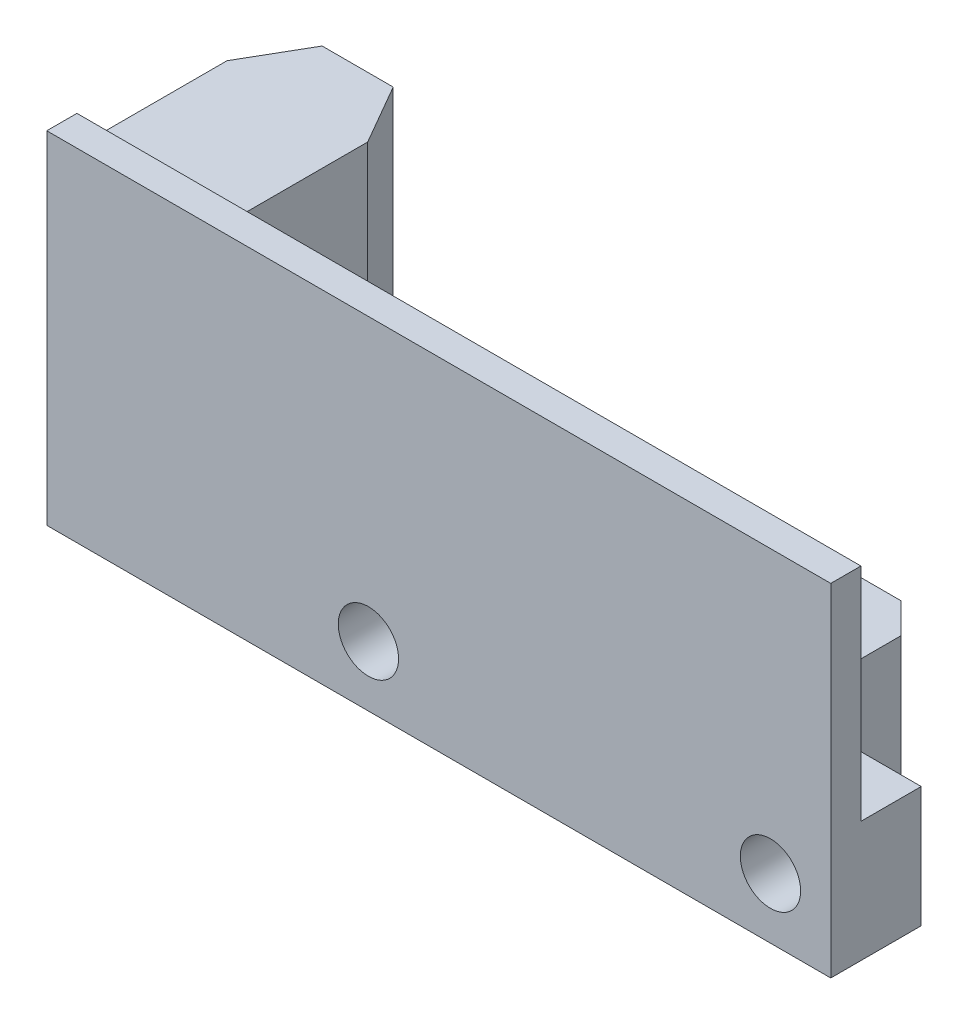
from build123d import *

# Parameters (mm, degrees)
ESQUISSE1_W             = 39
ESQUISSE1_H             = 17
BOSS_EXTRU_1_DEPTH      = 1.5
BOSS_EXTRU_2_DEPTH      = 6
ESQUISSE2_R             = 1.5
ENL_V_MAT_EXTRU_1_DEPTH = 13
CHANFREIN1_SIZE         = 1.5
ESQUISSE4_W             = 7
ESQUISSE4_H             = 15
BOSS_EXTRU_3_DEPTH      = 10
CHANFREIN2_SIZE         = 3
CHANFREIN2_SIZE2        = 1.732050808
CHANFREIN2_PART_2_SIZE  = 3
CHANFREIN2_PART_2_SIZE2 = 1.732050808


with BuildPart() as part:
    # Esquisse1 → Boss.-Extru.1 (new body)
    with BuildSketch(Plane.XY):
        Rectangle(ESQUISSE1_W, ESQUISSE1_H)
    extrude(amount=BOSS_EXTRU_1_DEPTH)

    # Esquisse3 → Boss.-Extru.2 (add)
    with BuildSketch(Plane(origin=(0, -8.5, 0), x_dir=(1, 0, 0), z_dir=(0, 1, 0))):
        Polygon((19.5, 0), (19.5, 3), (12.5, 3), (12.5, 10.5), (8.5, 10.5), (8.5, 3), (5.5, 3), (5.5, 10.5), (1.5, 10.5), (1.5, 3), (-5.5, 3), (-5.5, 0), align=None)
    extrude(amount=BOSS_EXTRU_2_DEPTH)

    # Esquisse2 → Enlèv. mat.-Extru.1 (cut, through all)
    with BuildSketch(Plane.XY.offset(1.5)):
        with Locations((16.5, -5.5)):
            Circle(ESQUISSE2_R)
        with Locations((-3.5, -5.5)):
            Circle(ESQUISSE2_R)
    extrude(amount=-ENL_V_MAT_EXTRU_1_DEPTH, mode=Mode.SUBTRACT)

    # Chanfrein1
    chanfrein1_edges = [part.edges().sort_by_distance(p)[0] for p in [
        (12.5, -5.5, -10.5),
    ]]
    chamfer(chanfrein1_edges, length=CHANFREIN1_SIZE)

    # Esquisse4 → Boss.-Extru.3 (add)
    with BuildSketch(Plane(origin=(0, 0, 0), x_dir=(-1, 0, 0), z_dir=(0, 0, -1))):
        with Locations((15.534193906, 0)):
            Rectangle(ESQUISSE4_W, ESQUISSE4_H)
    extrude(amount=BOSS_EXTRU_3_DEPTH)

    # Chanfrein2
    chanfrein2_edges = [part.edges().sort_by_distance(p)[0] for p in [
        (-12.034193906, 0, -10),
    ]]
    chanfrein2_side = [part.faces().sort_by_distance(p)[0] for p in [
        (-12.034193906, 0, -5),
    ]]
    chamfer(chanfrein2_edges, length=CHANFREIN2_SIZE, length2=CHANFREIN2_SIZE2, reference=chanfrein2_side[0])

    # Chanfrein2 part 2
    chanfrein2_part_2_edges = [part.edges().sort_by_distance(p)[0] for p in [
        (-19.034193906, 0, -10),
    ]]
    chanfrein2_part_2_side = [part.faces().sort_by_distance(p)[0] for p in [
        (-19.034193906, 0, -5),
    ]]
    chamfer(chanfrein2_part_2_edges, length=CHANFREIN2_PART_2_SIZE, length2=CHANFREIN2_PART_2_SIZE2, reference=chanfrein2_part_2_side[0])


solid = part.part
